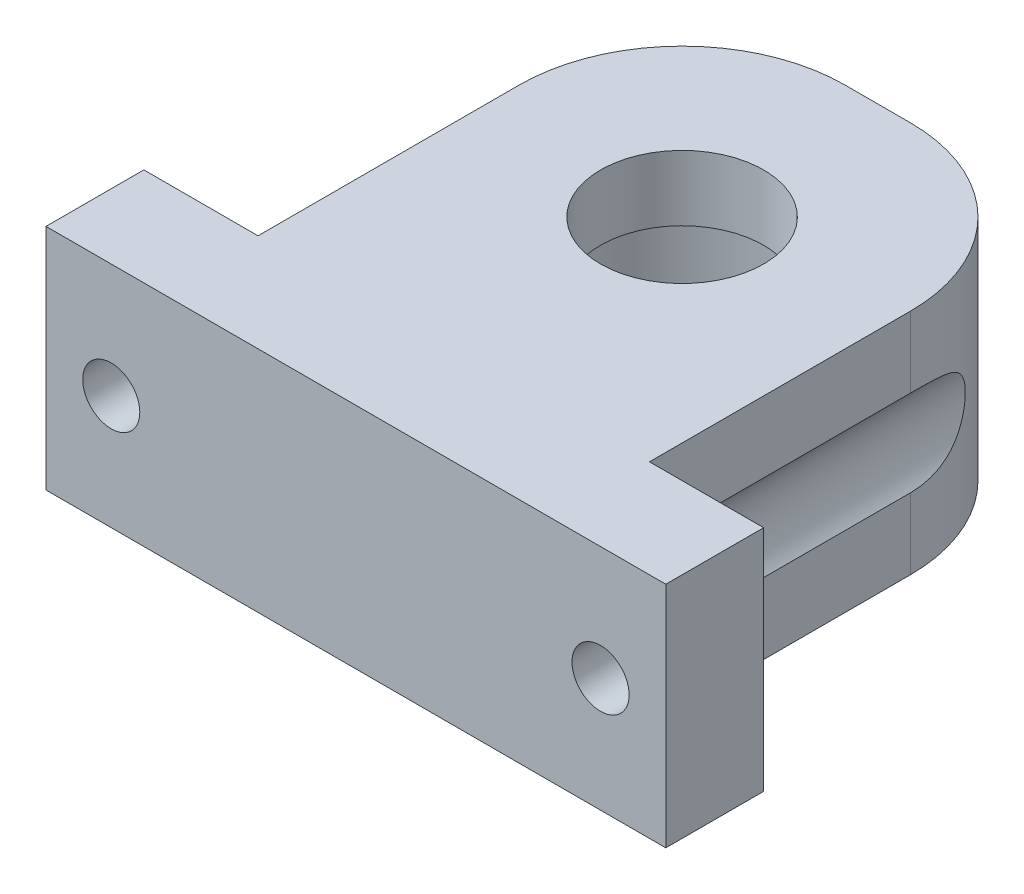
from build123d import *

# Parameters (mm, degrees)
BOSS_EXTRUDE1_DEPTH      = 7
BOSS_EXTRUDE1_DEPTH_BACK = 7
SKETCH1_R                = 8.15
CUT_EXTRUDE1_REACH       = 39.868
SKETCH2_R                = 1.75
FILLET1_R                = 10
SKETCH3_R                = 8.998813241
SKETCH3_R_2              = 5
BOSS_EXTRUDE2_DEPTH      = 4
CUT_EXTRUDE2_REACH       = 34.955
SKETCH4_R                = 4


with BuildPart() as part:
    # Sketch1 → Boss-Extrude1 (new, two sides: drawn at the far end of the back side and taken through both)
    with BuildSketch(Plane(origin=(0, 0, 0), x_dir=(1, 0, 0), z_dir=(0, 1, 0)).offset(-BOSS_EXTRUDE1_DEPTH_BACK)):
        Polygon((-19, 6), (-19, 0), (19, 0), (19, 6), (12, 6), (12, 32), (-12, 32), (-12, 6), align=None)
        with Locations((0, 20)):
            Circle(SKETCH1_R, mode=Mode.SUBTRACT)
    extrude(amount=BOSS_EXTRUDE1_DEPTH + BOSS_EXTRUDE1_DEPTH_BACK)

    # Sketch2 → Cut-Extrude1 (cut, up to next)
    with BuildSketch(Plane.XY, mode=Mode.PRIVATE) as cut_extrude1_sk1:
        with Locations((-15, 0)):
            Circle(SKETCH2_R)
    cut_extrude1_tool1 = extrude(cut_extrude1_sk1.sketch, amount=-CUT_EXTRUDE1_REACH, mode=Mode.PRIVATE) & part.part
    # Sketch2 → Cut-Extrude1 (cut, up to next)
    with BuildSketch(Plane.XY, mode=Mode.PRIVATE) as cut_extrude1_sk2:
        with Locations((15, 0)):
            Circle(SKETCH2_R)
    cut_extrude1_tool2 = extrude(cut_extrude1_sk2.sketch, amount=-CUT_EXTRUDE1_REACH, mode=Mode.PRIVATE) & part.part
    add(cut_extrude1_tool1.solids().sort_by_distance((-15, 0, 0))[0], mode=Mode.SUBTRACT)
    add(cut_extrude1_tool2.solids().sort_by_distance((15, 0, 0))[0], mode=Mode.SUBTRACT)

    # Fillet1
    fillet1_edges = [part.edges().sort_by_distance(p)[0] for p in [
        (-12, 0, -32),
        (12, 0, -32),
    ]]
    fillet(fillet1_edges, radius=FILLET1_R)

    # Sketch3 → Boss-Extrude2 (add)
    with BuildSketch(Plane(origin=(0, 7, 0), x_dir=(1, 0, 0), z_dir=(0, 1, 0))):
        with Locations((0, 20)):
            Circle(SKETCH3_R)
        with Locations((0, 20)):
            Circle(SKETCH3_R_2, mode=Mode.SUBTRACT)
    extrude(amount=-BOSS_EXTRUDE2_DEPTH)

    # Sketch4 → Cut-Extrude2 (cut, up to next)
    with BuildSketch(Plane(origin=(0, 0, -6), x_dir=(-1, 0, 0), z_dir=(0, 0, -1)), mode=Mode.PRIVATE) as cut_extrude2_sk1:
        with Locations((15, 0)):
            Circle(SKETCH4_R)
    cut_extrude2_tool1 = extrude(cut_extrude2_sk1.sketch, amount=CUT_EXTRUDE2_REACH, mode=Mode.PRIVATE) & part.part
    # Sketch4 → Cut-Extrude2 (cut, up to next)
    with BuildSketch(Plane(origin=(0, 0, -6), x_dir=(-1, 0, 0), z_dir=(0, 0, -1)), mode=Mode.PRIVATE) as cut_extrude2_sk2:
        with Locations((-15, 0)):
            Circle(SKETCH4_R)
    cut_extrude2_tool2 = extrude(cut_extrude2_sk2.sketch, amount=CUT_EXTRUDE2_REACH, mode=Mode.PRIVATE) & part.part
    add(cut_extrude2_tool1.solids().sort_by_distance((-15, 0, -6))[0], mode=Mode.SUBTRACT)
    add(cut_extrude2_tool2.solids().sort_by_distance((15, 0, -6))[0], mode=Mode.SUBTRACT)


solid = part.part
